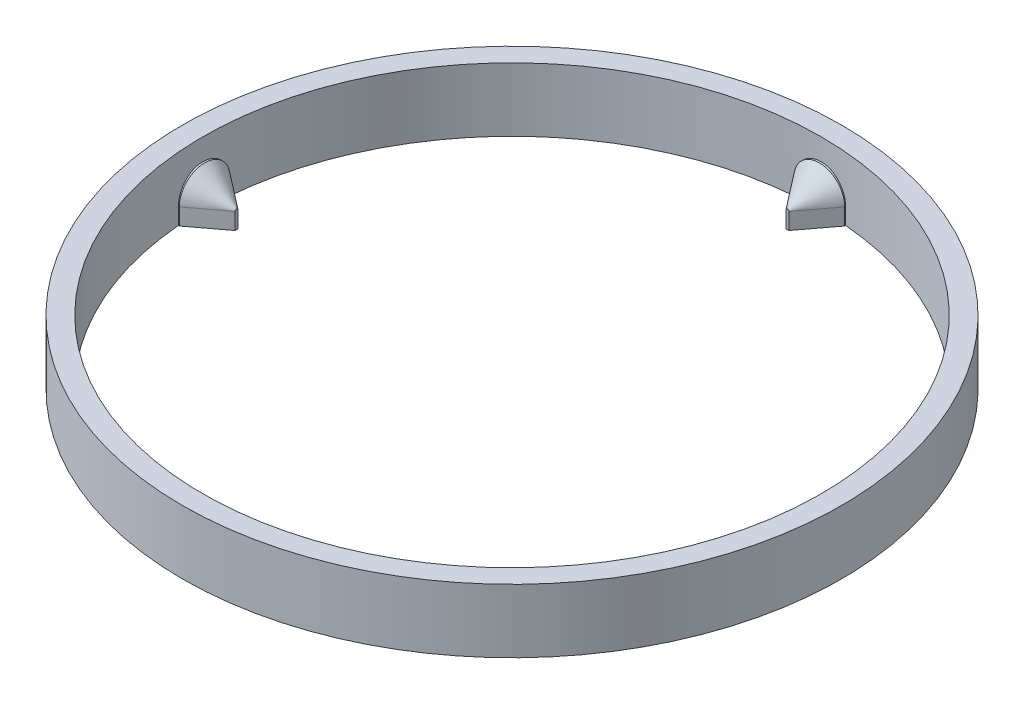
from build123d import *
from OCP.BRepFilletAPI import BRepFilletAPI_MakeChamfer

# Parameters (mm, degrees)
SKETCH_1_R                            = 51.8
SKETCH_1_R_2                          = 48.6
EXTRUDE_1_DEPTH                       = 10
EXTRUDE_START                         = 43.299942
EXTRUDE_4_DEPTH                       = 5.300058
CHAMFER_1_SIZE                        = 5
CHAMFER_1_SIZE2                       = 3.767770251
PATTERN_CIRCULAR_4_COUNT              = 4
CHAMFER_1_OF_PATTERN_CIRCULAR_4_SIZE  = 5
CHAMFER_1_OF_PATTERN_CIRCULAR_4_SIZE2 = 3.767770251


with BuildPart() as part:
    # 草图1 → 凸台-拉伸1 (new body)
    with BuildSketch(Plane(origin=(0, 0, 0), x_dir=(1, 0, 0), z_dir=(0, 1, 0))):
        with Locations(Location((0, 0, 0), (0, 0, 90))):
            Circle(SKETCH_1_R)
        with Locations(Location((0, 0, 0), (0, 0, 90))):
            Circle(SKETCH_1_R_2, mode=Mode.SUBTRACT)
    extrude(amount=EXTRUDE_1_DEPTH)

    # 草图2 → 凸台-拉伸4 (add)
    with BuildSketch(Plane.XY.offset(EXTRUDE_START)):
        with BuildLine():
            Line((4, 2.6), (4, 0))
            Line((4, 0), (-4, 0))
            Line((-4, 0), (-4, 2.6))
            ThreePointArc((-4, 2.6), (0, 6.6), (4, 2.6))
        make_face()
    extrude_4 = extrude(amount=EXTRUDE_4_DEPTH)

    # 倒角1: one chamfer whose edges measure the first distance from different faces: ONE call of the kernel's chamfer builder (chamfer() names one face for all edges)
    chamfer_1_edges_1 = [part.edges().sort_by_distance(p)[0] for p in [
        (0, 6.6, 43.299942),
    ]]
    chamfer_1_side_1 = [part.faces().sort_by_distance(p)[0] for p in [
        (0, 6.6, 45.95017715),
    ]]
    chamfer_1_edges_2 = [part.edges().sort_by_distance(p)[0] for p in [
        (4, 1.3, 43.299942),
    ]]
    chamfer_1_side_2 = [part.faces().sort_by_distance(p)[0] for p in [
        (4, 1.3, 45.867526616),
    ]]
    chamfer_1 = BRepFilletAPI_MakeChamfer(part.part.solid().wrapped)
    for e in chamfer_1_edges_1:
        chamfer_1.Add(CHAMFER_1_SIZE, CHAMFER_1_SIZE2, e.wrapped, chamfer_1_side_1[0].wrapped)  # the first distance lies on this face
    for e in chamfer_1_edges_2:
        chamfer_1.Add(CHAMFER_1_SIZE, CHAMFER_1_SIZE2, e.wrapped, chamfer_1_side_2[0].wrapped)  # the first distance lies on this face
    add(Compound.cast(chamfer_1.Shape()), mode=Mode.REPLACE)

    # 阵列(圆周)4: 凸台-拉伸4 ×4 about axis
    pattern_circular_4_axis = Axis((0, 0, 0), (0, 1, 0))
    for i in range(1, PATTERN_CIRCULAR_4_COUNT):
        add(extrude_4.rotate(pattern_circular_4_axis, i * 360 / PATTERN_CIRCULAR_4_COUNT))

    # 倒角1 of 阵列(圆周)4: one chamfer whose edges measure the first distance from different faces: ONE call of the kernel's chamfer builder (chamfer() names one face for all edges)
    chamfer_1_of_pattern_circular_4_edges_1 = [part.edges().sort_by_distance(p)[0] for p in [
        (43.299942, 6.6, 0),
    ]]
    chamfer_1_of_pattern_circular_4_side_1 = [part.faces().sort_by_distance(p)[0] for p in [
        (45.95017715, 6.6, 0),
    ]]
    chamfer_1_of_pattern_circular_4_edges_2 = [part.edges().sort_by_distance(p)[0] for p in [
        (43.299942, 1.3, -4),
    ]]
    chamfer_1_of_pattern_circular_4_side_2 = [part.faces().sort_by_distance(p)[0] for p in [
        (45.867526616, 1.3, -4),
    ]]
    chamfer_1_of_pattern_circular_4_edges_3 = [part.edges().sort_by_distance(p)[0] for p in [
        (0, 6.6, -43.299942),
    ]]
    chamfer_1_of_pattern_circular_4_side_3 = [part.faces().sort_by_distance(p)[0] for p in [
        (0, 6.6, -45.95017715),
    ]]
    chamfer_1_of_pattern_circular_4_edges_4 = [part.edges().sort_by_distance(p)[0] for p in [
        (-4, 1.3, -43.299942),
    ]]
    chamfer_1_of_pattern_circular_4_side_4 = [part.faces().sort_by_distance(p)[0] for p in [
        (-4, 1.3, -45.867526616),
    ]]
    chamfer_1_of_pattern_circular_4_edges_5 = [part.edges().sort_by_distance(p)[0] for p in [
        (-43.299942, 6.6, 0),
    ]]
    chamfer_1_of_pattern_circular_4_side_5 = [part.faces().sort_by_distance(p)[0] for p in [
        (-45.95017715, 6.6, 0),
    ]]
    chamfer_1_of_pattern_circular_4_edges_6 = [part.edges().sort_by_distance(p)[0] for p in [
        (-43.299942, 1.3, 4),
    ]]
    chamfer_1_of_pattern_circular_4_side_6 = [part.faces().sort_by_distance(p)[0] for p in [
        (-45.867526616, 1.3, 4),
    ]]
    chamfer_1_of_pattern_circular_4 = BRepFilletAPI_MakeChamfer(part.part.solid().wrapped)
    for e in chamfer_1_of_pattern_circular_4_edges_1:
        chamfer_1_of_pattern_circular_4.Add(CHAMFER_1_OF_PATTERN_CIRCULAR_4_SIZE, CHAMFER_1_OF_PATTERN_CIRCULAR_4_SIZE2, e.wrapped, chamfer_1_of_pattern_circular_4_side_1[0].wrapped)  # the first distance lies on this face
    for e in chamfer_1_of_pattern_circular_4_edges_2:
        chamfer_1_of_pattern_circular_4.Add(CHAMFER_1_OF_PATTERN_CIRCULAR_4_SIZE, CHAMFER_1_OF_PATTERN_CIRCULAR_4_SIZE2, e.wrapped, chamfer_1_of_pattern_circular_4_side_2[0].wrapped)  # the first distance lies on this face
    for e in chamfer_1_of_pattern_circular_4_edges_3:
        chamfer_1_of_pattern_circular_4.Add(CHAMFER_1_OF_PATTERN_CIRCULAR_4_SIZE, CHAMFER_1_OF_PATTERN_CIRCULAR_4_SIZE2, e.wrapped, chamfer_1_of_pattern_circular_4_side_3[0].wrapped)  # the first distance lies on this face
    for e in chamfer_1_of_pattern_circular_4_edges_4:
        chamfer_1_of_pattern_circular_4.Add(CHAMFER_1_OF_PATTERN_CIRCULAR_4_SIZE, CHAMFER_1_OF_PATTERN_CIRCULAR_4_SIZE2, e.wrapped, chamfer_1_of_pattern_circular_4_side_4[0].wrapped)  # the first distance lies on this face
    for e in chamfer_1_of_pattern_circular_4_edges_5:
        chamfer_1_of_pattern_circular_4.Add(CHAMFER_1_OF_PATTERN_CIRCULAR_4_SIZE, CHAMFER_1_OF_PATTERN_CIRCULAR_4_SIZE2, e.wrapped, chamfer_1_of_pattern_circular_4_side_5[0].wrapped)  # the first distance lies on this face
    for e in chamfer_1_of_pattern_circular_4_edges_6:
        chamfer_1_of_pattern_circular_4.Add(CHAMFER_1_OF_PATTERN_CIRCULAR_4_SIZE, CHAMFER_1_OF_PATTERN_CIRCULAR_4_SIZE2, e.wrapped, chamfer_1_of_pattern_circular_4_side_6[0].wrapped)  # the first distance lies on this face
    add(Compound.cast(chamfer_1_of_pattern_circular_4.Shape()), mode=Mode.REPLACE)


solid = part.part
